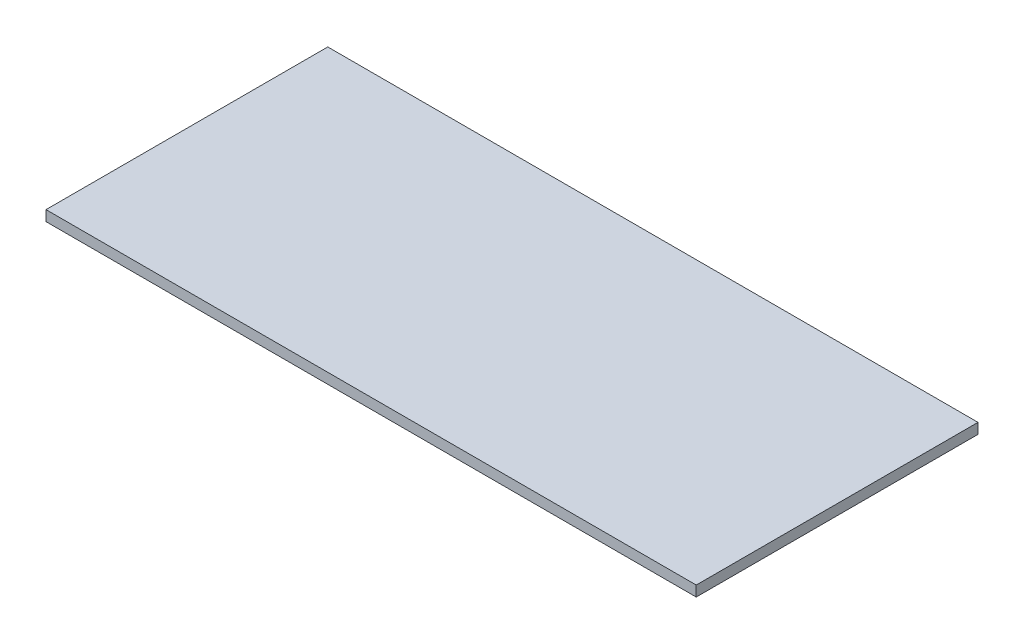
from build123d import *

# Parameters (mm, degrees)
SKETCH1_W           = 381
SKETCH1_H           = 165.1
BOSS_EXTRUDE1_DEPTH = 6.11


with BuildPart() as part:
    # Sketch1 → Boss-Extrude1 (new body)
    with BuildSketch(Plane(origin=(0, 0, 0), x_dir=(1, 0, 0), z_dir=(0, 1, 0))):
        Rectangle(SKETCH1_W, SKETCH1_H)
    extrude(amount=BOSS_EXTRUDE1_DEPTH)


solid = part.part
